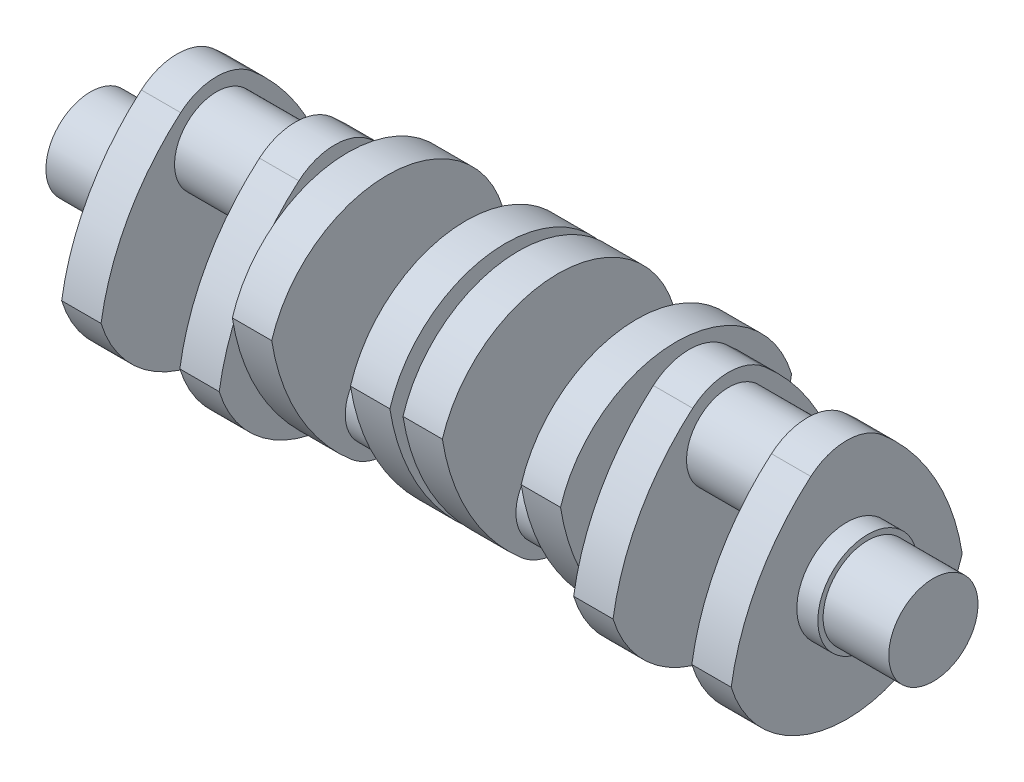
from build123d import *

# Parameters (mm, degrees)
SKETCH1_R           = 17
BOSS_EXTRUDE1_DEPTH = 25
SKETCH1_3_R         = 19
BOSS_EXTRUDE2_DEPTH = 8
BOSS_EXTRUDE3_DEPTH = 15
SKETCH3_R           = 16
BOSS_EXTRUDE4_DEPTH = 15
SKETCH4_R           = 17
BOSS_EXTRUDE5_DEPTH = 5
BOSS_EXTRUDE6_DEPTH = 15
SKETCH6_R           = 16
BOSS_EXTRUDE7_DEPTH = 30
BOSS_EXTRUDE8_DEPTH = 15
SKETCH8_R           = 17
BOSS_EXTRUDE9_DEPTH = 2.5


with BuildPart() as part:
    # Sketch1 → Boss-Extrude1 (new body)
    with BuildSketch(Plane(origin=(0, 0, 0), x_dir=(0, 0, -1), z_dir=(1, 0, 0))):
        Circle(SKETCH1_R)
    extrude(amount=-BOSS_EXTRUDE1_DEPTH)

    # Sketch1_3 → Boss-Extrude2 (add)
    with BuildSketch(Plane(origin=(0, 0, 0), x_dir=(0, 0, -1), z_dir=(1, 0, 0))):
        Circle(SKETCH1_3_R)
    extrude(amount=BOSS_EXTRUDE2_DEPTH)

    # Sketch2 → Boss-Extrude3 (add)
    with BuildSketch(Plane(origin=(8, 0, 0), x_dir=(0, 0, -1), z_dir=(1, 0, 0))):
        with BuildLine():
            ThreePointArc((-13.668094758, 40.943123461), (0, 46), (13.668094758, 40.943123461))
            ThreePointArc((13.668094758, 40.943123461), (33.683444249, 16.469257624), (44, -13.416407865))
            ThreePointArc((44, -13.416407865), (0, -46), (-44, -13.416407865))
            ThreePointArc((-44, -13.416407865), (-33.683444249, 16.469257624), (-13.668094758, 40.943123461))
        make_face()
    boss_extrude3 = extrude(amount=BOSS_EXTRUDE3_DEPTH)

    # Sketch3 → Boss-Extrude4 (add)
    with BuildSketch(Plane(origin=(23, 0, 0), x_dir=(0, 0, -1), z_dir=(1, 0, 0))):
        with Locations((0, 25)):
            Circle(SKETCH3_R)
    boss_extrude4 = extrude(amount=BOSS_EXTRUDE4_DEPTH)

    # Mirror1: Boss-Extrude3, Boss-Extrude4 across plane
    add(boss_extrude3.mirror(Plane(origin=(38, 25, 0), x_dir=(0, 0, 1), z_dir=(1, 0, 0))))
    add(boss_extrude4.mirror(Plane(origin=(38, 25, 0), x_dir=(0, 0, 1), z_dir=(1, 0, 0))))

    # Sketch4 → Boss-Extrude5 (add)
    with BuildSketch(Plane(origin=(68, 0, 0), x_dir=(0, 0, -1), z_dir=(1, 0, 0))):
        Circle(SKETCH4_R)
    extrude(amount=BOSS_EXTRUDE5_DEPTH)

    # Sketch5 → Boss-Extrude6 (add)
    with BuildSketch(Plane(origin=(73, 0, 0), x_dir=(0, 0, -1), z_dir=(1, 0, 0))):
        with BuildLine():
            ThreePointArc((-13.668094758, -40.943123461), (0, -46), (13.668094758, -40.943123461))
            ThreePointArc((13.668094758, -40.943123461), (33.683444249, -16.469257624), (44, 13.416407865))
            ThreePointArc((44, 13.416407865), (0, 46), (-44, 13.416407865))
            ThreePointArc((-44, 13.416407865), (-33.683444249, -16.469257624), (-13.668094758, -40.943123461))
        make_face()
    extrude(amount=BOSS_EXTRUDE6_DEPTH)

    # Sketch6 → Boss-Extrude7 (add)
    with BuildSketch(Plane(origin=(88, 0, 0), x_dir=(0, 0, -1), z_dir=(1, 0, 0))):
        with Locations((0, -25)):
            Circle(SKETCH6_R)
    extrude(amount=BOSS_EXTRUDE7_DEPTH)

    # Sketch7 → Boss-Extrude8 (add)
    with BuildSketch(Plane(origin=(118, 0, 0), x_dir=(0, 0, -1), z_dir=(1, 0, 0))):
        with BuildLine():
            ThreePointArc((-13.668094758, -40.943123461), (0, -46), (13.668094758, -40.943123461))
            ThreePointArc((13.668094758, -40.943123461), (33.683444249, -16.469257624), (44, 13.416407865))
            ThreePointArc((44, 13.416407865), (0, 46), (-44, 13.416407865))
            ThreePointArc((-44, 13.416407865), (-33.683444249, -16.469257624), (-13.668094758, -40.943123461))
        make_face()
    extrude(amount=BOSS_EXTRUDE8_DEPTH)

    # Sketch8 → Boss-Extrude9 (add)
    with BuildSketch(Plane(origin=(133, 0, 0), x_dir=(0, 0, -1), z_dir=(1, 0, 0))):
        Circle(SKETCH8_R)
    extrude(amount=BOSS_EXTRUDE9_DEPTH)

    # Mirror2: part across plane


with BuildPart() as part_1:
    add(part.part)
    add(part.part.mirror(Plane(origin=(135.5, 0, 0), x_dir=(0, 0, 1), z_dir=(1, 0, 0))))


solid = part_1.part
